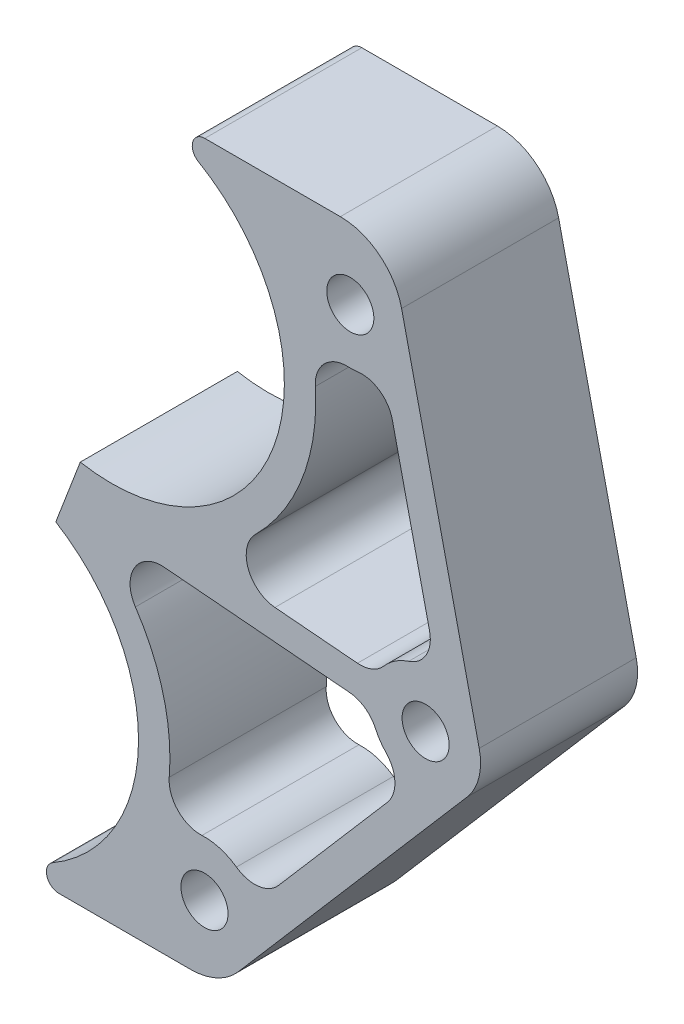
from build123d import *

# Parameters (mm, degrees)
SKETCH1_R           = 4.7625
BOSS_EXTRUDE1_DEPTH = 31.75
SKETCH2_R           = 2.4892
CUT_EXTRUDE1_DEPTH  = 25.4
SKETCH3_W           = 64.987057328
SKETCH3_H           = 9.244924149
SKETCH3_W_2         = 60.957372158
SKETCH3_H_2         = 11.477125068
CUT_EXTRUDE2_DEPTH  = 32.7500001
FILLET1_R           = 2.54
FILLET2_R           = 12.7


with BuildPart() as part:
    # Sketch1 → Boss-Extrude1 (new body)
    with BuildSketch(Plane.XY):
        with BuildLine():
            Line((-12.474995441, -32.621007246), (-17.01135742, -44.483191699))
            ThreePointArc((-17.01135742, -44.483191699), (4.857819156, -83.447185108), (-29.486352861, -112.029198945))
            Line((-29.486352861, -112.029198945), (-29.486352861, -117.566398945))
            Line((-29.486352861, -117.566398945), (17.033444212, -117.566398945))
            Line((17.033444212, -117.566398945), (71.902434201, -53.852584939))
            ThreePointArc((71.902434201, -53.852584939), (74.265423414, -49.285430405), (74.319342365, -44.143474424))
            Line((74.319342365, -44.143474424), (55.334619846, 39.5732))
            Line((55.334619846, 39.5732), (0, 39.5732))
            Line((0, 39.5732), (0, 34.925))
            ThreePointArc((0, 34.925), (34.344172017, -6.342986163), (-12.474995441, -32.621007246))
        make_face()
        with Locations((18.773647139, -98.516398945)):
            Circle(SKETCH1_R, mode=Mode.SUBTRACT)
        with BuildLine():
            ThreePointArc((4.805346172, -54.132368316), (4.611000081, -47.373075962), (10.619637037, -44.271127306))
            Line((10.619637037, -44.271127306), (48.106372009, -47.462477992))
            ThreePointArc((48.106372009, -47.462477992), (51.235190632, -48.60574982), (53.354739272, -51.17559223))
            ThreePointArc((53.354739272, -51.17559223), (54.288815903, -52.843916254), (55.495053497, -54.327423945))
            ThreePointArc((55.495053497, -54.327423945), (57.278420501, -58.558773894), (55.742748768, -62.886178727))
            Line((55.742748768, -62.886178727), (33.730414898, -88.446877882))
            ThreePointArc((33.730414898, -88.446877882), (29.678710415, -90.607528488), (25.229617999, -89.471616111))
            ThreePointArc((25.229617999, -89.471616111), (21.919602705, -87.858508918), (18.264177504, -87.415583797))
            ThreePointArc((18.264177504, -87.415583797), (13.399411545, -85.477293546), (11.645131351, -80.543185934))
            ThreePointArc((11.645131351, -80.543185934), (10.470460882, -66.756317013), (4.805346172, -54.132368316))
        make_face(mode=Mode.SUBTRACT)
        with Locations((63.482010487, -46.601094008)):
            Circle(SKETCH1_R, mode=Mode.SUBTRACT)
        with BuildLine():
            Line((49.704289076, -41.541119878), (33.019297292, -40.120679821))
            ThreePointArc((33.019297292, -40.120679821), (27.589635384, -35.961933342), (29.083549865, -29.28775772))
            ThreePointArc((29.083549865, -29.28775772), (38.598079931, -14.622374999), (41.18881011, 2.665998258))
            ThreePointArc((41.18881011, 2.665998258), (42.985049027, 7.515335292), (47.792622808, 9.420532987))
            ThreePointArc((47.792622808, 9.420532987), (48.759316239, 9.421923517), (49.722231073, 9.507323433))
            ThreePointArc((49.722231073, 9.507323433), (54.184633542, 8.424879689), (56.750552758, 4.616890871))
            Line((56.750552758, 4.616890871), (64.280599338, -28.588253807))
            ThreePointArc((64.280599338, -28.588253807), (63.608310734, -33.130582317), (60.049355437, -36.032057365))
            ThreePointArc((60.049355437, -36.032057365), (57.324876061, -37.350291237), (55.057143591, -39.354765694))
            ThreePointArc((55.057143591, -39.354765694), (52.644006558, -41.092556671), (49.704289076, -41.541119878))
        make_face(mode=Mode.SUBTRACT)
        with Locations((48.26, 20.5232)):
            Circle(SKETCH1_R, mode=Mode.SUBTRACT)
    extrude(amount=BOSS_EXTRUDE1_DEPTH)

    # Sketch2 → Cut-Extrude1 (cut)
    with BuildSketch(Plane(origin=(0, 0, 0), x_dir=(0, 0, 1), z_dir=(-0.934030272, 0.357193857, 0))):
        with Locations((7.9375, -41.275)):
            Circle(SKETCH2_R)
        with Locations((23.8125, -41.275)):
            Circle(SKETCH2_R)
    extrude(amount=-CUT_EXTRUDE1_DEPTH, mode=Mode.SUBTRACT)

    # Sketch3 → Cut-Extrude2 (cut, through all)
    with BuildSketch(Plane.XY.offset(31.75)):
        Polygon((-17.01135742, -44.483191699), (-12.474995441, -32.621007246), (-5.676500584, -32.621007246), (-11.862088463, -48.795771234), align=None)
        with Locations((32.493528664, 39.547462075)):
            Rectangle(SKETCH3_W, SKETCH3_H)
        with Locations((0.992333218, -117.767761479)):
            Rectangle(SKETCH3_W_2, SKETCH3_H_2)
    extrude(amount=-CUT_EXTRUDE2_DEPTH, mode=Mode.SUBTRACT)

    # Fillet1
    fillet1_edges = [part.edges().sort_by_distance(p)[0] for p in [
        (-29.486352861, -112.029198945, 15.875),
        (0, 34.925, 15.875),
    ]]
    fillet(fillet1_edges, radius=FILLET1_R)

    # Fillet2
    fillet2_edges = [part.edges().sort_by_distance(p)[0] for p in [
        (56.388708387, 34.925, 15.875),
        (21.801963819, -112.029198945, 15.875),
    ]]
    fillet(fillet2_edges, radius=FILLET2_R)


solid = part.part
